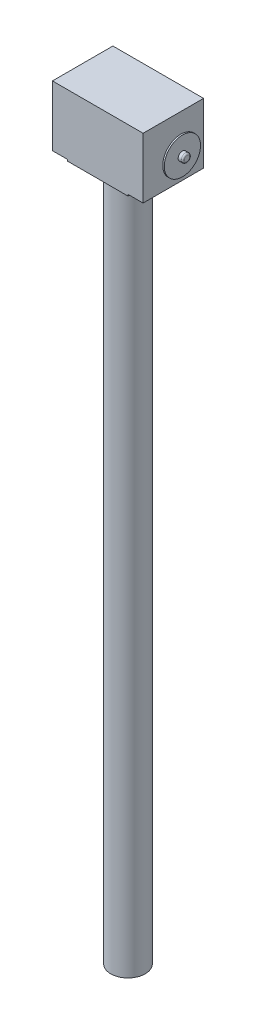
from build123d import *

# Parameters (mm, degrees)
SKETCH1_W           = 300
SKETCH1_H           = 200
BOSS_EXTRUDE1_DEPTH = 200
SKETCH2_R           = 14
BOSS_EXTRUDE2_DEPTH = 25
SKETCH3_R           = 60
BOSS_EXTRUDE3_DEPTH = 5
SKETCH4_R           = 14
BOSS_EXTRUDE4_DEPTH = 15
FILLET1_R           = 5
SKETCH5_W           = 200
SKETCH5_H           = 200
BOSS_EXTRUDE5_DEPTH = 5
SKETCH6_R           = 57
BOSS_EXTRUDE6_DEPTH = 2300


with BuildPart() as part:
    # Sketch1 → Boss-Extrude1 (new body)
    with BuildSketch(Plane(origin=(0, 0, 0), x_dir=(1, 0, 0), z_dir=(0, 1, 0))):
        Rectangle(SKETCH1_W, SKETCH1_H)
    extrude(amount=BOSS_EXTRUDE1_DEPTH)

    # Sketch2 → Boss-Extrude2 (add)
    with BuildSketch(Plane(origin=(150, 0, 0), x_dir=(0, 0, -1), z_dir=(1, 0, 0))):
        with Locations((0, 100)):
            Circle(SKETCH2_R)
    extrude(amount=BOSS_EXTRUDE2_DEPTH)

    # Sketch3 → Boss-Extrude3 (add)
    with BuildSketch(Plane(origin=(175, 0, 0), x_dir=(0, 0, -1), z_dir=(1, 0, 0))):
        with Locations((0, 100)):
            Circle(SKETCH3_R)
    extrude(amount=BOSS_EXTRUDE3_DEPTH)

    # Sketch4 → Boss-Extrude4 (add)
    with BuildSketch(Plane(origin=(180, 0, 0), x_dir=(0, 0, -1), z_dir=(1, 0, 0))):
        with Locations((0, 100)):
            Circle(SKETCH4_R)
    extrude(amount=BOSS_EXTRUDE4_DEPTH)

    # Fillet1
    fillet1_edges = [part.edges().sort_by_distance(p)[0] for p in [
        (195, 100, 14),
    ]]
    fillet(fillet1_edges, radius=FILLET1_R)

    # Sketch5 → Boss-Extrude5 (add)
    with BuildSketch(Plane.XZ):
        Rectangle(SKETCH5_W, SKETCH5_H)
    extrude(amount=BOSS_EXTRUDE5_DEPTH)

    # Sketch6 → Boss-Extrude6 (add)
    with BuildSketch(Plane.XZ.offset(5)):
        Circle(SKETCH6_R)
    extrude(amount=BOSS_EXTRUDE6_DEPTH)


solid = part.part
